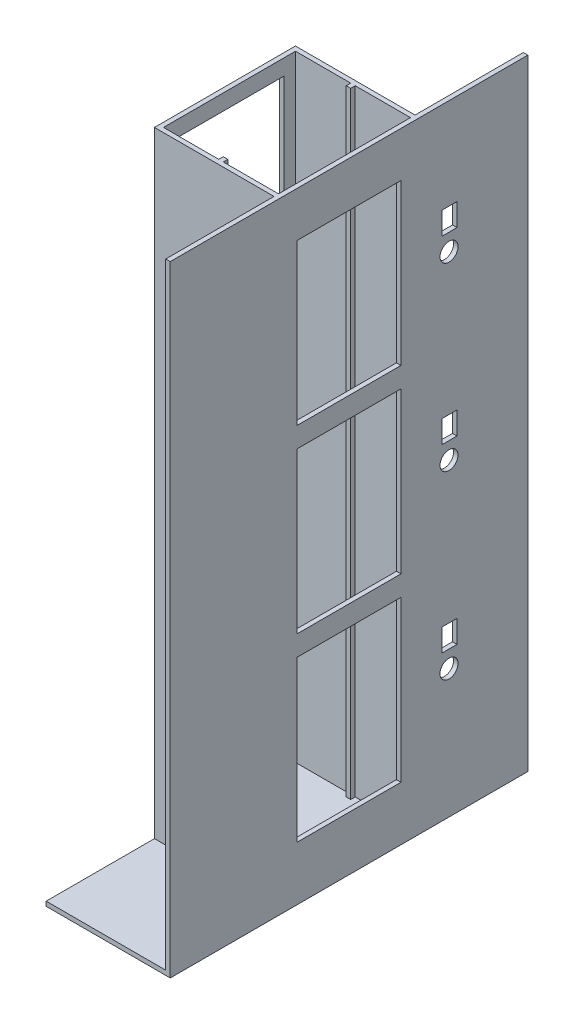
from build123d import *

# Parameters (mm, degrees)
ESQUISSE1_W             = 102
ESQUISSE1_H             = 546
BOSS_EXTRU_1_DEPTH      = 125
ESQUISSE2_W             = 117
ESQUISSE2_H             = 546
ENL_V_MAT_EXTRU_1_DEPTH = 570.3373341
ESQUISSE3_W             = 4
ESQUISSE3_H             = 546
BOSS_EXTRU_2_DEPTH      = 4
ESQUISSE4_W             = 4
ESQUISSE4_H             = 546
BOSS_EXTRU_3_DEPTH      = 4
ESQUISSE5_W             = 125
ESQUISSE5_H             = 546
BOSS_EXTRU_4_DEPTH      = 4
ESQUISSE6_W             = 97
ESQUISSE6_H             = 518
ENL_V_MAT_EXTRU_2_DEPTH = 571.067539858
ESQUISSE7_W             = 317
ESQUISSE7_H             = 546
BOSS_EXTRU_5_DEPTH      = 4
ESQUISSE8_W             = 92
ESQUISSE8_H             = 142
ENL_V_MAT_EXTRU_3_DEPTH = 600.21365138
ESQUISSE10_W            = 13.2
ESQUISSE10_H            = 20
ENL_V_MAT_EXTRU_4_DEPTH = 600.21365138
ESQUISSE12_R            = 8
ENL_V_MAT_EXTRU_5_DEPTH = 600.21365138
ESQUISSE13_W            = 110
ESQUISSE13_H            = 317
BOSS_EXTRU_6_DEPTH      = 4


with BuildPart() as part:
    # Esquisse1 → Boss.-Extru.1 (new body)
    with BuildSketch(Plane.XY):
        with Locations((51, 273)):
            Rectangle(ESQUISSE1_W, ESQUISSE1_H)
    extrude(amount=BOSS_EXTRU_1_DEPTH)

    # Esquisse2 → Enlèv. mat.-Extru.1 (cut, through all)
    with BuildSketch(Plane(origin=(102, 0, 0), x_dir=(0, 0, -1), z_dir=(1, 0, 0))):
        with Locations((-62.5, 273)):
            Rectangle(ESQUISSE2_W, ESQUISSE2_H)
    extrude(amount=-ENL_V_MAT_EXTRU_1_DEPTH, mode=Mode.SUBTRACT)


with BuildPart() as enl_v_mat_extru_1_piece_1:
    # of the separate pieces the step leaves, piece 1, a body of its own (enl_v_mat_extru_1_pieces)
    add(part.part.solids().sort_by_distance((102, 0, 121))[0])

    # Esquisse3 → Boss.-Extru.2 (add)
    with BuildSketch(Plane(origin=(0, 0, 121), x_dir=(-1, 0, 0), z_dir=(0, 0, -1))):
        with Locations((-51, 273)):
            Rectangle(ESQUISSE3_W, ESQUISSE3_H)
    extrude(amount=BOSS_EXTRU_2_DEPTH)

    # Esquisse5 → Boss.-Extru.4 (add)
    with BuildSketch(Plane.ZY):
        with Locations((62.5, 273)):
            Rectangle(ESQUISSE5_W, ESQUISSE5_H)
    extrude(amount=BOSS_EXTRU_4_DEPTH)

    # Esquisse6 → Enlèv. mat.-Extru.2 (cut, through all)
    with BuildSketch(Plane.ZY.offset(4)):
        with Locations((62.5, 273)):
            Rectangle(ESQUISSE6_W, ESQUISSE6_H)
    extrude(amount=-ENL_V_MAT_EXTRU_2_DEPTH, mode=Mode.SUBTRACT)



with BuildPart() as enl_v_mat_extru_1_piece_2:
    # of the separate pieces the step leaves, piece 2, a body of its own (enl_v_mat_extru_1_pieces)
    add(part.part.solids().sort_by_distance((0, 0, 0))[0])

    # Esquisse4 → Boss.-Extru.3 (add)
    with BuildSketch(Plane.XY.offset(4)):
        with Locations((51, 273)):
            Rectangle(ESQUISSE4_W, ESQUISSE4_H)
    extrude(amount=BOSS_EXTRU_3_DEPTH)


with BuildPart() as enl_v_mat_extru_1_piece_1_1:
    add(enl_v_mat_extru_1_piece_1.part)

    add(enl_v_mat_extru_1_piece_2.part)  # Boss.-Extru.5 merges Enlèv. mat.-Extru.1 piece 2
    # Esquisse7 → Boss.-Extru.5 (add)
    with BuildSketch(Plane(origin=(102, 0, 0), x_dir=(0, 0, -1), z_dir=(1, 0, 0))):
        with Locations((-62.5, 273)):
            Rectangle(ESQUISSE7_W, ESQUISSE7_H)
    extrude(amount=BOSS_EXTRU_5_DEPTH)

    # Esquisse8 → Enlèv. mat.-Extru.3 (cut, through all)
    with BuildSketch(Plane(origin=(106, 0, 0), x_dir=(0, 0, -1), z_dir=(1, 0, 0))):
        with Locations((-62.5, 115)):
            Rectangle(ESQUISSE8_W, ESQUISSE8_H)
        with Locations((-62.5, 275)):
            Rectangle(ESQUISSE8_W, ESQUISSE8_H)
        with Locations((-62.5, 435)):
            Rectangle(ESQUISSE8_W, ESQUISSE8_H)
    extrude(amount=-ENL_V_MAT_EXTRU_3_DEPTH, mode=Mode.SUBTRACT)

    # Esquisse10 → Enlèv. mat.-Extru.4 (cut, through all)
    with BuildSketch(Plane(origin=(106, 0, 0), x_dir=(0, 0, -1), z_dir=(1, 0, 0))):
        with Locations((26.6, 135)):
            Rectangle(ESQUISSE10_W, ESQUISSE10_H)
        with Locations((26.6, 295)):
            Rectangle(ESQUISSE10_W, ESQUISSE10_H)
        with Locations((26.6, 455)):
            Rectangle(ESQUISSE10_W, ESQUISSE10_H)
    extrude(amount=-ENL_V_MAT_EXTRU_4_DEPTH, mode=Mode.SUBTRACT)

    # Esquisse12 → Enlèv. mat.-Extru.5 (cut, through all)
    with BuildSketch(Plane(origin=(106, 0, 0), x_dir=(0, 0, -1), z_dir=(1, 0, 0))):
        with Locations((26.125, 110)):
            Circle(ESQUISSE12_R)
        with Locations((26.125, 270)):
            Circle(ESQUISSE12_R)
        with Locations((26.125, 430)):
            Circle(ESQUISSE12_R)
    extrude(amount=-ENL_V_MAT_EXTRU_5_DEPTH, mode=Mode.SUBTRACT)

    # Esquisse13 → Boss.-Extru.6 (add)
    with BuildSketch(Plane.XZ):
        with Locations((51, 62.5)):
            Rectangle(ESQUISSE13_W, ESQUISSE13_H)
    extrude(amount=BOSS_EXTRU_6_DEPTH)


solid = enl_v_mat_extru_1_piece_1_1.part
